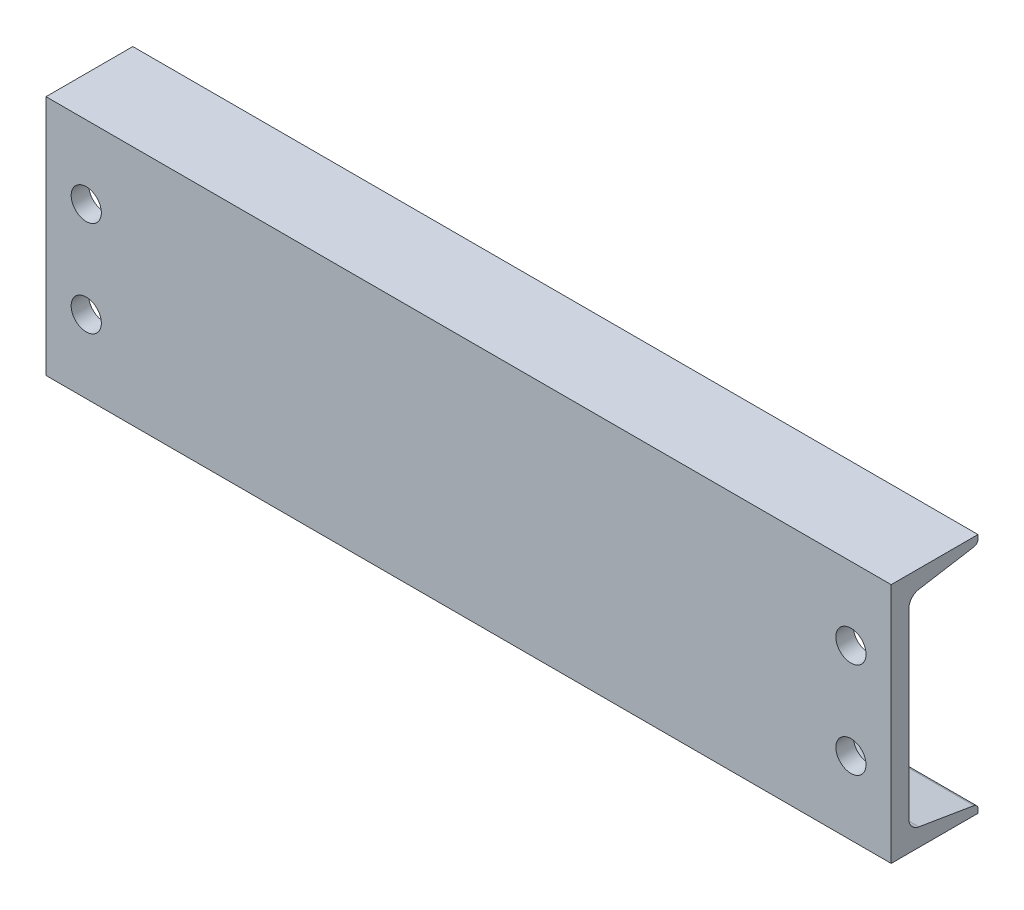
from build123d import *

# Parameters (mm, degrees)
BOSS_EXTRUDE1_DEPTH = 266.7
CUT_EXTRUDE1_REACH  = 56.788
SKETCH2_R           = 9.525


with BuildPart() as part:
    # Sketch1 → Boss-Extrude1 (new body, symmetric)
    with BuildSketch(Plane(origin=(0, 0, 0), x_dir=(0, 0, -1), z_dir=(1, 0, 0))):
        with BuildLine():
            Line((-27.3939, -76.2), (-27.3939, 76.2))
            Line((-27.3939, 76.2), (27.3939, 76.2))
            Line((27.3939, 76.2), (27.3939, 73.710744653))
            ThreePointArc((27.3939, 73.710744653), (26.67159656, 71.740607726), (24.84702368, 70.704221901))
            Line((24.84702368, 70.704221901), (-9.926909199, 64.908143628))
            ThreePointArc((-9.926909199, 64.908143628), (-14.488341399, 62.317179067), (-16.2941, 57.391836749))
            Line((-16.2941, 57.391836749), (-16.2941, -57.391836749))
            ThreePointArc((-16.2941, -57.391836749), (-14.488341399, -62.317179067), (-9.926909199, -64.908143628))
            Line((-9.926909199, -64.908143628), (24.84702368, -70.704221901))
            ThreePointArc((24.84702368, -70.704221901), (26.67159656, -71.740607726), (27.3939, -73.710744653))
            Line((27.3939, -73.710744653), (27.3939, -76.2))
            Line((27.3939, -76.2), (-27.3939, -76.2))
        make_face()
    extrude(amount=BOSS_EXTRUDE1_DEPTH, both=True)

    # Sketch2 → Cut-Extrude1 (cut, up to next)
    with BuildSketch(Plane.XY.offset(27.3939), mode=Mode.PRIVATE) as cut_extrude1_sk1:
        with Locations((-241.3, 30.1625)):
            Circle(SKETCH2_R)
    cut_extrude1_tool1 = extrude(cut_extrude1_sk1.sketch, amount=-CUT_EXTRUDE1_REACH, mode=Mode.PRIVATE) & part.part
    add(cut_extrude1_tool1.solids().sort_by_distance((-241.3, 30.1625, 27.3939))[0], mode=Mode.SUBTRACT)
    # Sketch2 → Cut-Extrude1 (cut, up to next)
    with BuildSketch(Plane.XY.offset(27.3939), mode=Mode.PRIVATE) as cut_extrude1_sk2:
        with Locations((-241.3, -30.1625)):
            Circle(SKETCH2_R)
    cut_extrude1_tool2 = extrude(cut_extrude1_sk2.sketch, amount=-CUT_EXTRUDE1_REACH, mode=Mode.PRIVATE) & part.part
    add(cut_extrude1_tool2.solids().sort_by_distance((-241.3, -30.1625, 27.3939))[0], mode=Mode.SUBTRACT)
    # Sketch2 → Cut-Extrude1 (cut, up to next)
    with BuildSketch(Plane.XY.offset(27.3939), mode=Mode.PRIVATE) as cut_extrude1_sk3:
        with Locations((241.3, -30.1625)):
            Circle(SKETCH2_R)
    cut_extrude1_tool3 = extrude(cut_extrude1_sk3.sketch, amount=-CUT_EXTRUDE1_REACH, mode=Mode.PRIVATE) & part.part
    add(cut_extrude1_tool3.solids().sort_by_distance((241.3, -30.1625, 27.3939))[0], mode=Mode.SUBTRACT)
    # Sketch2 → Cut-Extrude1 (cut, up to next)
    with BuildSketch(Plane.XY.offset(27.3939), mode=Mode.PRIVATE) as cut_extrude1_sk4:
        with Locations((241.3, 30.1625)):
            Circle(SKETCH2_R)
    cut_extrude1_tool4 = extrude(cut_extrude1_sk4.sketch, amount=-CUT_EXTRUDE1_REACH, mode=Mode.PRIVATE) & part.part
    add(cut_extrude1_tool4.solids().sort_by_distance((241.3, 30.1625, 27.3939))[0], mode=Mode.SUBTRACT)


solid = part.part
